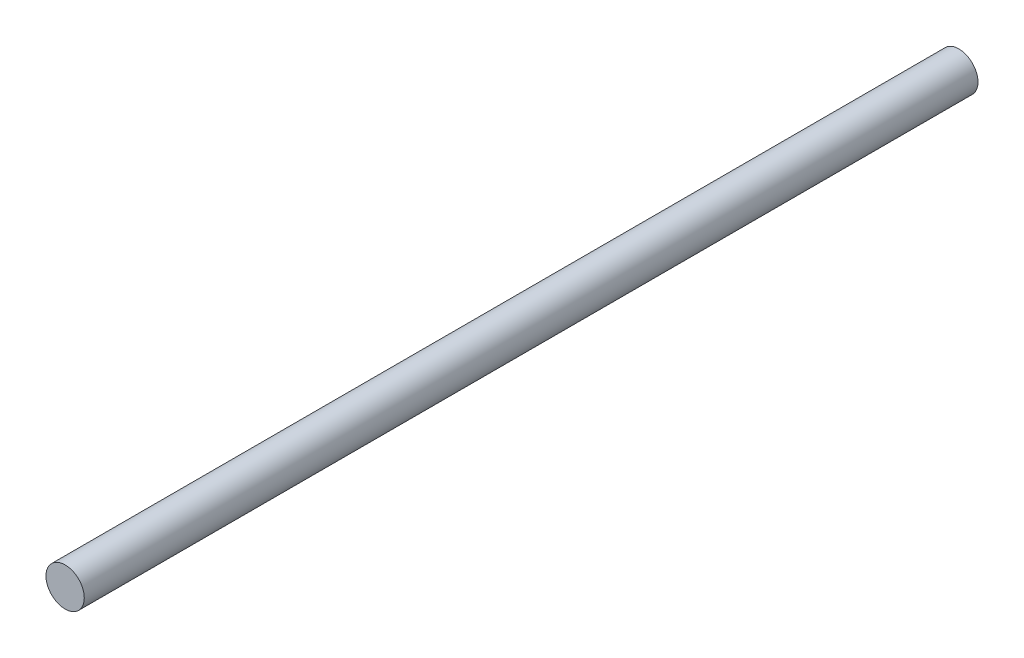
from build123d import *

# Parameters (mm, degrees)
SKETCH_1_R      = 1.5
EXTRUDE_1_DEPTH = 70


with BuildPart() as part:
    # 草图1 → 凸台-拉伸1 (new body)
    with BuildSketch(Plane.XY):
        with Locations((-1.250502385, 4.458831289)):
            Circle(SKETCH_1_R)
    extrude(amount=EXTRUDE_1_DEPTH)


solid = part.part
